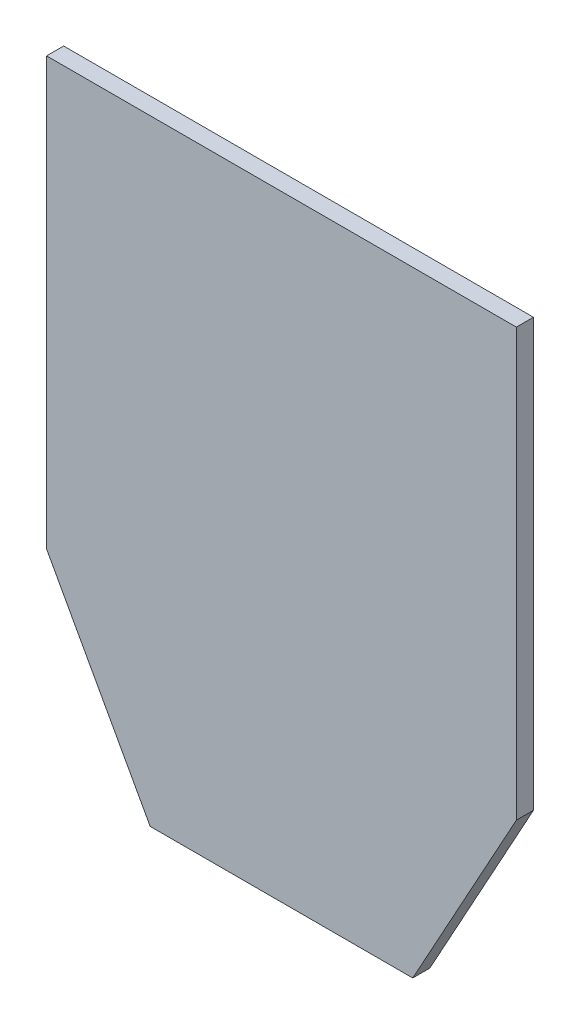
from build123d import *

# Parameters (mm, degrees)
BOSS_EXTRUDE1_DEPTH = 4


with BuildPart() as part:
    # Sketch1 → Boss-Extrude1 (new body)
    with BuildSketch(Plane.XY):
        Polygon((-38.508619801, 29.117647675), (71.491380199, 29.117647675), (71.491380199, -70.882352325), (47.231042356, -115.007969839), (-14.248281957, -115.007969839), (-38.508619801, -70.882352325), align=None)
    extrude(amount=BOSS_EXTRUDE1_DEPTH)


solid = part.part
